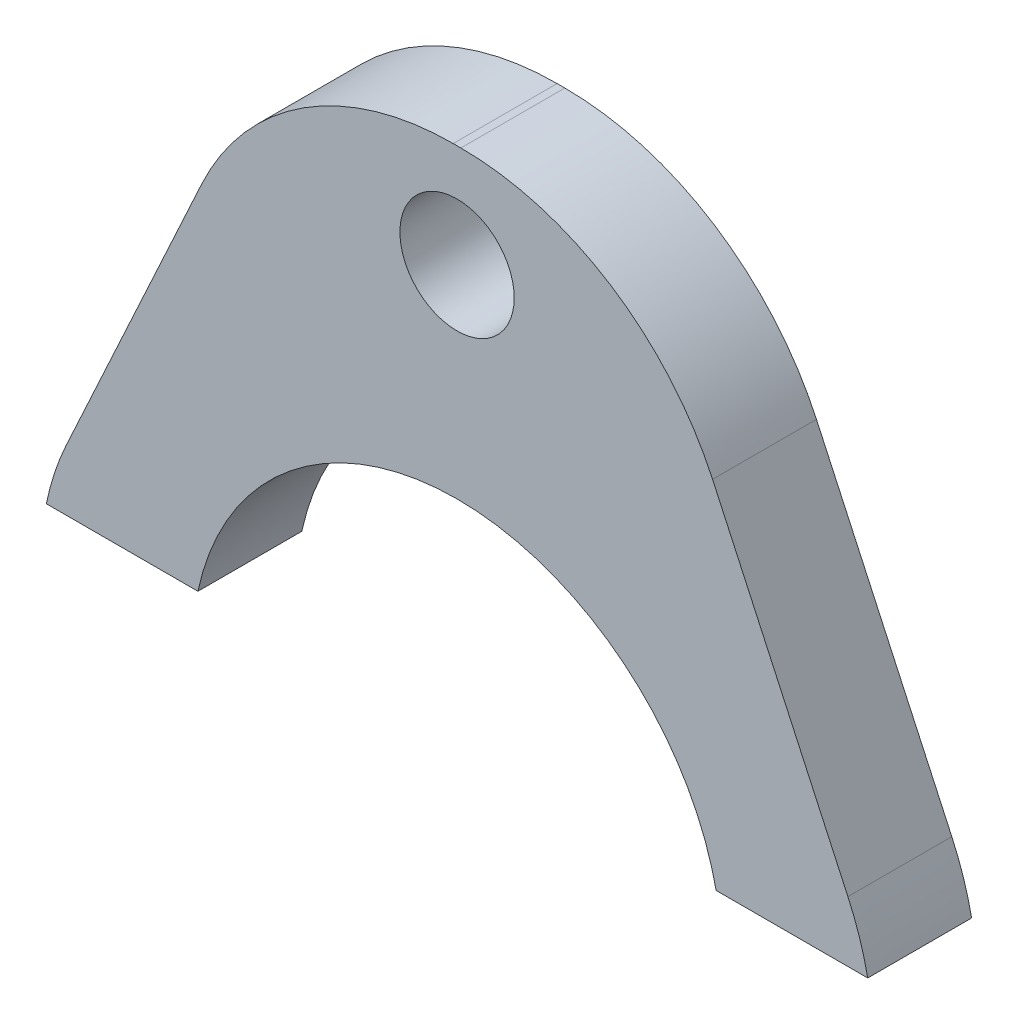
from build123d import *

# Parameters (mm, degrees)
ESBO_O1_R                = 1.65
RESSALTO_EXTRUS_O1_DEPTH = 3
FILETE1_R                = 8


with BuildPart() as part:
    # Esboço1 → Ressalto-extrusão1 (new body)
    with BuildSketch(Plane.XY):
        with BuildLine():
            Line((-5.233177242, 16.48), (-11.2845681, 3.348148148))
            ThreePointArc((-11.2845681, 3.348148148), (-11.621333239, 2.490590121), (-11.85726917, 1.6))
            Line((-11.85726917, 1.6), (-7.48080878, 1.6))
            ThreePointArc((-7.48080878, 1.6), (0, 7.65), (7.48080878, 1.6))
            Line((7.48080878, 1.6), (11.85726917, 1.6))
            ThreePointArc((11.85726917, 1.6), (11.621333239, 2.490590121), (11.2845681, 3.348148148))
            Line((11.2845681, 3.348148148), (5.233177242, 16.48))
            Line((5.233177242, 16.48), (-5.233177242, 16.48))
        make_face()
        with Locations((0, 13.5)):
            Circle(ESBO_O1_R, mode=Mode.SUBTRACT)
    extrude(amount=RESSALTO_EXTRUS_O1_DEPTH)

    # Filete1
    filete1_edges = [part.edges().sort_by_distance(p)[0] for p in [
        (-5.233177242, 16.48, 1.5),
        (5.233177242, 16.48, 1.5),
    ]]
    fillet(filete1_edges, radius=FILETE1_R)


solid = part.part
